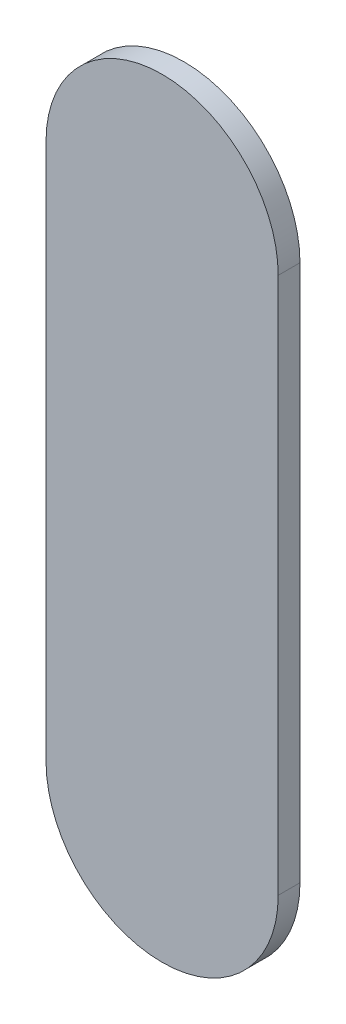
from build123d import *

# Parameters (mm, degrees)
BOSS_EXTRUDE1_DEPTH = 1.5


with BuildPart() as part:
    # Sketch1 → Boss-Extrude1 (new body)
    with BuildSketch(Plane.XY):
        with BuildLine():
            Line((-8, 18.5), (-8, -18.5))
            ThreePointArc((-8, -18.5), (0, -26.5), (8, -18.5))
            Line((8, -18.5), (8, 18.5))
            ThreePointArc((8, 18.5), (0, 26.5), (-8, 18.5))
        make_face()
    extrude(amount=BOSS_EXTRUDE1_DEPTH)


solid = part.part
